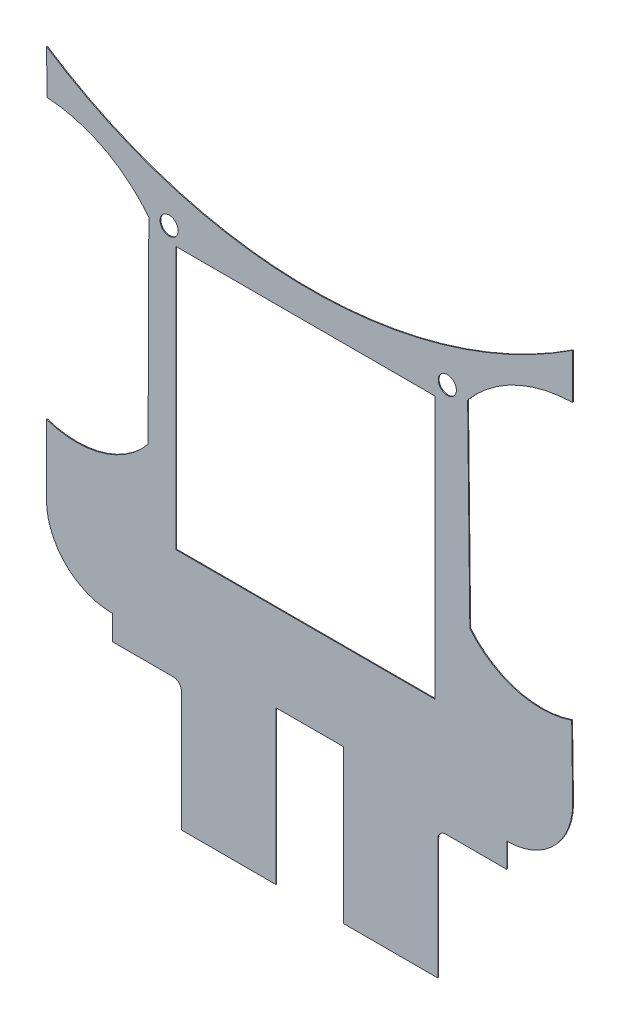
from build123d import *

# Parameters (mm, degrees)
MODEL_R                 = 1.105480949
SALIENTE_EXTRUIR1_DEPTH = 0.1


with BuildPart() as part:
    # Model → Saliente-Extruir1 (new body)
    with BuildSketch(Plane.XY):
        with BuildLine():
            Line((51.143384, -35.053134749), (51.143384, -20.385289094))
            ThreePointArc((51.143384, -20.385289094), (51.426053418, -19.68453986), (52.1199065, -19.385341948))
            Line((52.1199065, -19.385341948), (59.562610667, -19.385341948))
            Line((59.562610667, -19.385341948), (59.562610667, -17.385341948))
            Line((59.562610667, -17.385341948), (59.562610667, -16.385341948))
            Line((59.562610667, -16.385341948), (59.695317333, -16.385341948))
            ThreePointArc((59.695317333, -16.385341948), (65.261252438, -14.057943719), (67.588650667, -8.492008614))
            Line((67.588650667, -8.492008614), (67.463691144, 0.313086794))
            ThreePointArc((67.463691144, 0.313086794), (60.715005996, 0.09791285), (55.052059002, 3.775151269))
            Line((55.052059002, 3.775151269), (54.782677463, 27.772447041))
            ThreePointArc((54.782677463, 27.772447041), (60.525183262, 32.220247397), (67.588650667, 33.913389175))
            Line((67.588650667, 33.913389175), (67.588650667, 39.418409961))
            ThreePointArc((67.588650667, 39.418409961), (35.521984, 29.806750722), (3.455317333, 39.418409961))
            Line((3.455317333, 39.418409961), (3.545697938, 34.065337225))
            ThreePointArc((3.545697938, 34.065337225), (10.429922022, 32.177547893), (15.929001679, 27.626019279))
            Line((15.929001679, 27.626019279), (15.840502335, 3.627374762))
            ThreePointArc((15.840502335, 3.627374762), (10.205432608, -0.092442467), (3.455317333, 0.071858577))
            Line((3.455317333, 0.071858577), (3.455317333, -8.386134749))
            ThreePointArc((3.455317333, -8.386134749), (5.745129751, -14.020897609), (11.348650667, -16.386134749))
            Line((11.348650667, -16.386134749), (11.481357333, -16.386134749))
            Line((11.481357333, -16.386134749), (11.481357333, -19.386134749))
            Line((11.481357333, -19.386134749), (18.913917333, -19.386134749))
            ThreePointArc((18.913917333, -19.386134749), (19.614357448, -19.681789392), (19.900584, -20.386134749))
            Line((19.900584, -20.386134749), (19.900584, -35.053134749))
            Line((19.900584, -35.053134749), (31.411037333, -35.053134749))
            Line((31.411037333, -35.053134749), (31.411037333, -16.386134749))
            Line((31.411037333, -16.386134749), (39.632930667, -16.386134749))
            Line((39.632930667, -16.386134749), (39.632930667, -35.053134749))
            Line((39.632930667, -35.053134749), (51.143384, -35.053134749))
        make_face()
        Polygon((35.504038921, 26.200203798), (50.790705587, 26.200203798), (50.790705587, -5.799796202), (19.217372254, -5.799796202), (19.217372254, 26.200203798), align=None, mode=Mode.SUBTRACT)
        with Locations((18.402228125, 27.990495682)):
            Circle(MODEL_R, mode=Mode.SUBTRACT)
        with Locations((52.306774108, 28.11827167)):
            Circle(MODEL_R, mode=Mode.SUBTRACT)
    extrude(amount=SALIENTE_EXTRUIR1_DEPTH)


solid = part.part
